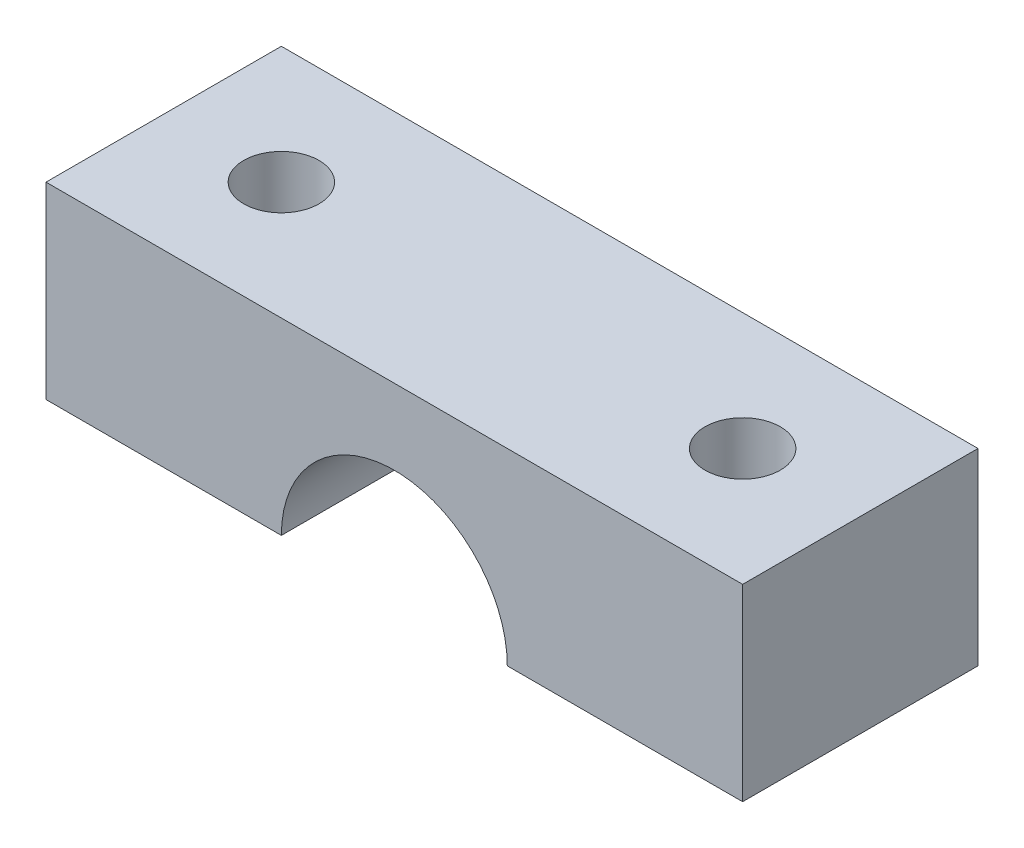
from build123d import *

# Parameters (mm, degrees)
SKETCH1_W           = 29.6
SKETCH1_H           = 10
BOSS_EXTRUDE1_DEPTH = 8
SKETCH2_R           = 4.8
CUT_EXTRUDE1_DEPTH  = 10
SKETCH4_R           = 1.6
CUT_EXTRUDE2_DEPTH  = 8
SKETCH7_R           = 1.6
CUT_EXTRUDE3_DEPTH  = 8


with BuildPart() as part:
    # Sketch1 → Boss-Extrude1 (new body)
    with BuildSketch(Plane(origin=(0, 0, 0), x_dir=(1, 0, 0), z_dir=(0, 1, 0))):
        with Locations((-14.8, 5)):
            Rectangle(SKETCH1_W, SKETCH1_H)
    extrude(amount=BOSS_EXTRUDE1_DEPTH)

    # Sketch2 → Cut-Extrude1 (cut)
    with BuildSketch(Plane.XY):
        with Locations((-14.8, 0)):
            Circle(SKETCH2_R)
    extrude(amount=-CUT_EXTRUDE1_DEPTH, mode=Mode.SUBTRACT)

    # Sketch4 → Cut-Extrude2 (cut)
    with BuildSketch(Plane.XZ):
        with Locations((-24.6, -5)):
            Circle(SKETCH4_R)
    extrude(amount=-CUT_EXTRUDE2_DEPTH, mode=Mode.SUBTRACT)

    # Sketch7 → Cut-Extrude3 (cut)
    with BuildSketch(Plane.XZ):
        with Locations((-5, -5)):
            Circle(SKETCH7_R)
    extrude(amount=-CUT_EXTRUDE3_DEPTH, mode=Mode.SUBTRACT)


solid = part.part
